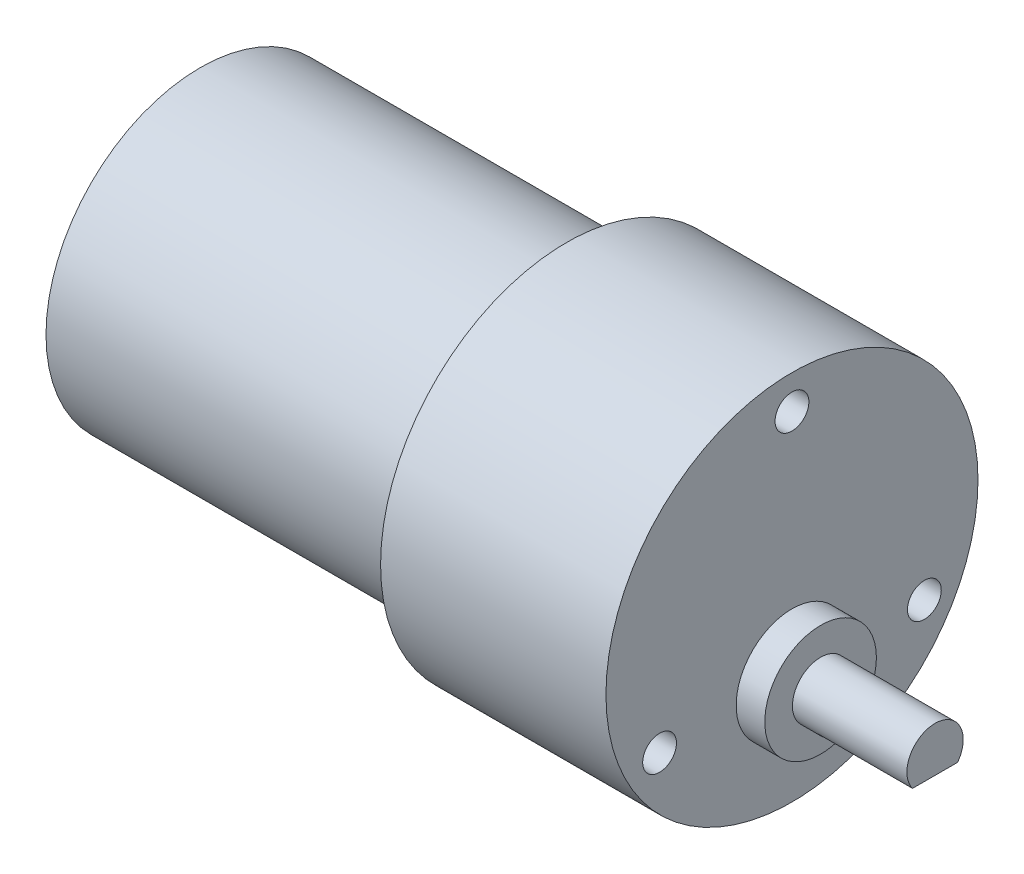
from build123d import *

# Parameters (mm, degrees)
SKETCH1_R           = 16.51
BOSS_EXTRUDE2_DEPTH = 20
SKETCH2_R           = 13.6906
BOSS_EXTRUDE3_DEPTH = 32.512
SKETCH3_R           = 1.5
CUT_EXTRUDE1_DEPTH  = 6.35
SKETCH4_R           = 4.953
BOSS_EXTRUDE4_DEPTH = 2.54
SKETCH5_R           = 2.5
BOSS_EXTRUDE5_DEPTH = 10.16
SKETCH6_R           = 5
BOSS_EXTRUDE6_DEPTH = 2
SKETCH7_R           = 1.143
BOSS_EXTRUDE7_DEPTH = 3.048
CUT_EXTRUDE2_DEPTH  = 8.382


with BuildPart() as part:
    # Sketch1 → Boss-Extrude2 (new body)
    with BuildSketch(Plane(origin=(0, 0, 0), x_dir=(0, 0, -1), z_dir=(1, 0, 0))):
        Circle(SKETCH1_R)
    extrude(amount=BOSS_EXTRUDE2_DEPTH)

    # Sketch2 → Boss-Extrude3 (add)
    with BuildSketch(Plane.ZY):
        Circle(SKETCH2_R)
    extrude(amount=BOSS_EXTRUDE3_DEPTH)

    # Sketch3 → Cut-Extrude1 (cut)
    with BuildSketch(Plane(origin=(20, 0, 0), x_dir=(0, 0, -1), z_dir=(1, 0, 0))):
        with Locations((0, 13.51)):
            Circle(SKETCH3_R)
        with Locations((11.75, -6.841596989)):
            Circle(SKETCH3_R)
        with Locations((-11.75, -6.841596989)):
            Circle(SKETCH3_R)
    extrude(amount=-CUT_EXTRUDE1_DEPTH, mode=Mode.SUBTRACT)

    # Sketch4 → Boss-Extrude4 (add)
    with BuildSketch(Plane(origin=(20, 0, 0), x_dir=(0, 0, -1), z_dir=(1, 0, 0))):
        with Locations((0, -6.604)):
            Circle(SKETCH4_R)
    extrude(amount=BOSS_EXTRUDE4_DEPTH)

    # Sketch5 → Boss-Extrude5 (add)
    with BuildSketch(Plane(origin=(22.54, 0, 0), x_dir=(0, 0, -1), z_dir=(1, 0, 0))):
        with Locations((0, -6.604)):
            Circle(SKETCH5_R)
    extrude(amount=BOSS_EXTRUDE5_DEPTH)

    # Sketch6 → Boss-Extrude6 (add)
    with BuildSketch(Plane.ZY.offset(32.512)):
        Circle(SKETCH6_R)
    extrude(amount=BOSS_EXTRUDE6_DEPTH)

    # Sketch7 → Boss-Extrude7 (add)
    with BuildSketch(Plane.ZY.offset(34.512)):
        Circle(SKETCH7_R)
    extrude(amount=BOSS_EXTRUDE7_DEPTH)

    # Sketch8 → Cut-Extrude2 (cut)
    with BuildSketch(Plane(origin=(32.7, 0, 0), x_dir=(0, 0, -1), z_dir=(1, 0, 0))):
        with BuildLine():
            Line((2, -8.104), (-2, -8.104))
            ThreePointArc((-2, -8.104), (0, -9.104), (2, -8.104))
        make_face()
    extrude(amount=-CUT_EXTRUDE2_DEPTH, mode=Mode.SUBTRACT)


solid = part.part
